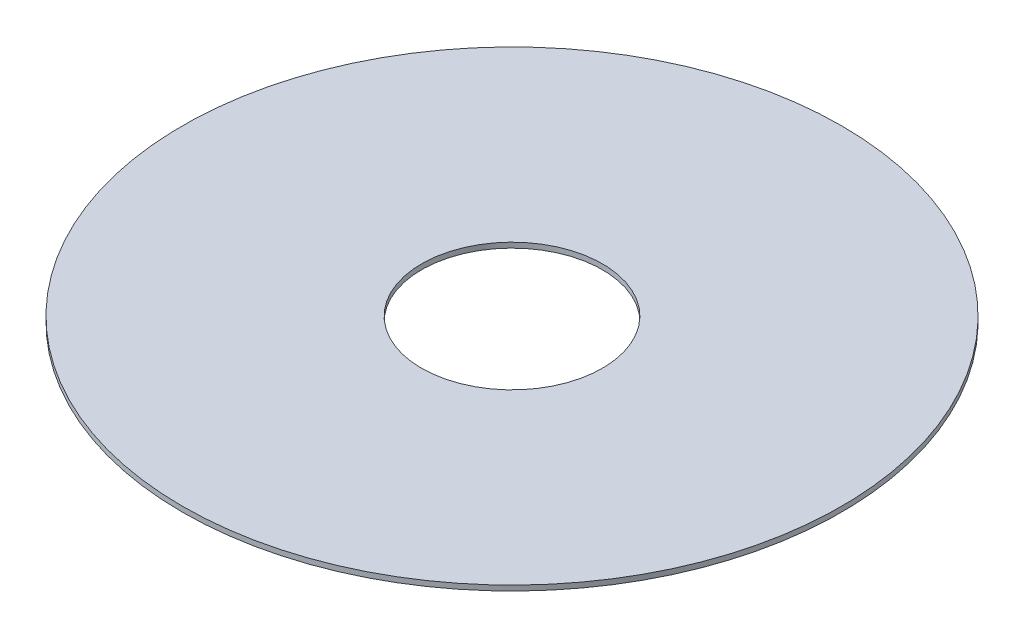
from build123d import *

# Parameters (mm, degrees)
SKIZZE1_R                            = 12.75
SKIZZE1_R_2                          = 3.5
AUFSATZ_LINEAR_AUSTRAGEN1_DEPTH      = 0.1
AUFSATZ_LINEAR_AUSTRAGEN1_DEPTH_BACK = 0.1


with BuildPart() as part:
    # Skizze1 → Aufsatz-Linear austragen1 (new body, two sides)
    with BuildSketch(Plane(origin=(0, 0, 0), x_dir=(1, 0, 0), z_dir=(0, 1, 0))) as aufsatz_linear_austragen1_sk:
        Circle(SKIZZE1_R)
        Circle(SKIZZE1_R_2, mode=Mode.SUBTRACT)
    extrude(amount=AUFSATZ_LINEAR_AUSTRAGEN1_DEPTH)
    extrude(aufsatz_linear_austragen1_sk.sketch, amount=-AUFSATZ_LINEAR_AUSTRAGEN1_DEPTH_BACK)


solid = part.part
